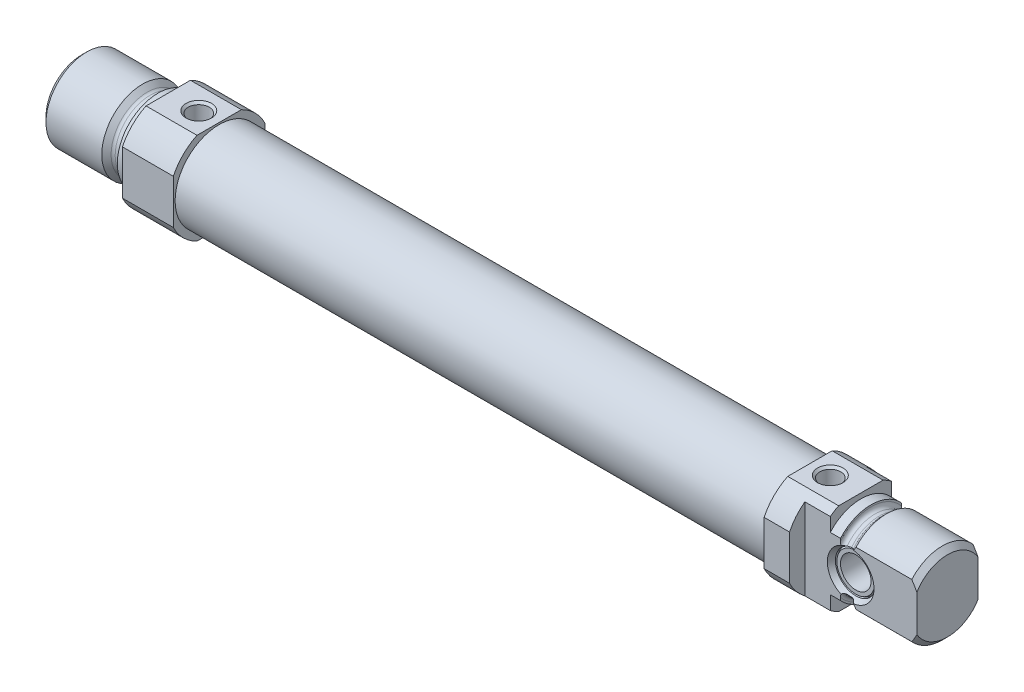
from build123d import *

# Parameters (mm, degrees)
BOSS_EXTRUDE1_DEPTH     = 10
SKETCH3_W               = 116
SKETCH3_H               = 8.65
SKETCH4_W               = 18
SKETCH4_H               = 18
BOSS_EXTRUDE2_DEPTH     = 10
SKETCH5_W               = 10
SKETCH5_H               = 10
CUT_EXTRUDE1_DEPTH      = 10
CUT_EXTRUDE1_DEPTH_BACK = 10
HOLE1_D                 = 4.134
HOLE1_DEPTH             = 9
HOLE1_CSINK_D           = 5
HOLE1_CSINK_ANGLE       = 90
HOLE2_D                 = 4.134
HOLE2_DEPTH             = 11
HOLE2_CSINK_D           = 5
HOLE2_CSINK_ANGLE       = 90
HOLE2_TIP               = 1.193383006


with BuildPart() as part:
    # Sketch1 → Revolve1 (revolve)
    with BuildSketch(Plane.XY):
        with BuildLine():
            Line((0, 0), (0, 7))
            Line((0, 7), (1, 8))
            Line((1, 8), (11.95, 8))
            Line((11.95, 8), (12.865685425, 7.084314575))
            ThreePointArc((12.865685425, 7.084314575), (13.125224104, 6.910896374), (13.43137085, 6.85))
            Line((13.43137085, 6.85), (14.2, 6.85))
            ThreePointArc((14.2, 6.85), (14.765685425, 7.084314575), (15, 7.65))
            Line((15, 7.65), (15, 8))
            Line((15, 8), (17, 8))
            Line((17, 8), (17, 0))
            Line((17, 0), (0, 0))
        make_face()
    revolve(axis=Axis((17, 0, 0), (-1, 0, 0)))

    # Sketch2 → Boss-Extrude1 (add)
    with BuildSketch(Plane(origin=(17, 0, 0), x_dir=(0, 0, -1), z_dir=(1, 0, 0))):
        with BuildLine():
            Line((-4.358898944, -9), (4.358898944, -9))
            ThreePointArc((4.358898944, -9), (7.071067812, -7.071067812), (9, -4.358898944))
            Line((9, -4.358898944), (9, 4.358898944))
            ThreePointArc((9, 4.358898944), (7.071067812, 7.071067812), (4.358898944, 9))
            Line((4.358898944, 9), (-4.358898944, 9))
            ThreePointArc((-4.358898944, 9), (-7.071067812, 7.071067812), (-9, 4.358898944))
            Line((-9, 4.358898944), (-9, -4.358898944))
            ThreePointArc((-9, -4.358898944), (-7.071067812, -7.071067812), (-4.358898944, -9))
        make_face()
    extrude(amount=BOSS_EXTRUDE1_DEPTH)

    # Sketch3 → Revolve2 (revolve)
    with BuildSketch(Plane.XY):
        with Locations((85, 4.325)):
            Rectangle(SKETCH3_W, SKETCH3_H)
    revolve(axis=Axis((143, 0, 0), (-1, 0, 0)))

    # Sketch4 → Boss-Extrude2 (add)
    with BuildSketch(Plane(origin=(143, 0, 0), x_dir=(0, 0, -1), z_dir=(1, 0, 0))):
        Rectangle(SKETCH4_W, SKETCH4_H)
    extrude(amount=BOSS_EXTRUDE2_DEPTH)

    # Sketch5 → Cut-Revolve1 (revolve, cut)
    with BuildSketch(Plane.XY):
        with Locations((148, 15)):
            Rectangle(SKETCH5_W, SKETCH5_H)
    revolve(axis=Axis((153, 0, 0), (-1, 0, 0)), mode=Mode.SUBTRACT)

    # Sketch6 → Revolve3 (revolve)
    with BuildSketch(Plane.XY):
        with BuildLine():
            Line((153, 0), (153, 8))
            Line((153, 8), (155, 8))
            Line((155, 8), (155, 7.65))
            ThreePointArc((155, 7.65), (155.234314575, 7.084314575), (155.8, 6.85))
            Line((155.8, 6.85), (156.56862915, 6.85))
            ThreePointArc((156.56862915, 6.85), (156.874775896, 6.910896374), (157.134314575, 7.084314575))
            Line((157.134314575, 7.084314575), (158.05, 8))
            Line((158.05, 8), (169, 8))
            Line((169, 8), (170, 7))
            Line((170, 7), (170, 0))
            Line((170, 0), (153, 0))
        make_face()
    revolve(axis=Axis((170, 0, 0), (-1, 0, 0)))

    # Sketch7 → Cut-Extrude1 (cut, two sides: drawn at the far end of the back side and taken through both)
    with BuildSketch(Plane(origin=(0, 0, 0), x_dir=(1, 0, 0), z_dir=(0, 1, 0)).offset(-CUT_EXTRUDE1_DEPTH_BACK)):
        Polygon((148, 18), (148, 6), (170, 6), (170, -6), (148, -6), (148, -18), (182, -18), (182, 18), align=None)
    extrude(amount=CUT_EXTRUDE1_DEPTH + CUT_EXTRUDE1_DEPTH_BACK, mode=Mode.SUBTRACT)

    # Sketch8 → Cut-Revolve2 (revolve, cut)
    with BuildSketch(Plane(origin=(157, 0, 0), x_dir=(0, 0, -1), z_dir=(1, 0, 0))):
        Polygon((-6.2, 0), (-6.2, 4.692820323), (-5, 4), (-4.5, 4), (-5, 3.711324865), (-5, 3), (5, 3), (5, 3.711324865), (4.5, 4), (5, 4), (6.2, 4.692820323), (6.2, 0), align=None)
    revolve(axis=Axis((157, 0, -5), (0, 0, 1)), mode=Mode.SUBTRACT)

    # Hole1
    with Locations(Plane(origin=(0, 9, 0), x_dir=(1, 0, 0), z_dir=(0, 1, 0))):
        with Locations((23, 0)):
            CounterSinkHole(HOLE1_D / 2, HOLE1_CSINK_D / 2, depth=HOLE1_DEPTH, counter_sink_angle=HOLE1_CSINK_ANGLE)

    # Hole2
    with Locations(Plane(origin=(0, 9, 0), x_dir=(1, 0, 0), z_dir=(0, 1, 0))):
        with Locations((147, 0)):
            CounterSinkHole(HOLE2_D / 2, HOLE2_CSINK_D / 2, depth=HOLE2_DEPTH, counter_sink_angle=HOLE2_CSINK_ANGLE)
            with Locations((0, 0, -(HOLE2_DEPTH + HOLE2_TIP / 2))):  # 120° drill point
                Cone(0, HOLE2_D / 2, HOLE2_TIP, mode=Mode.SUBTRACT)

    # Sketch13 → Cut-Revolve3 (revolve, cut)
    with BuildSketch(Plane.XY):
        Polygon((-5, 0), (-5, 3), (41.2, 3), (41.2, 8), (125.2, 8), (125.2, 0), align=None)
    revolve(axis=Axis((125.2, 0, 0), (-1, 0, 0)), mode=Mode.SUBTRACT)


solid = part.part
